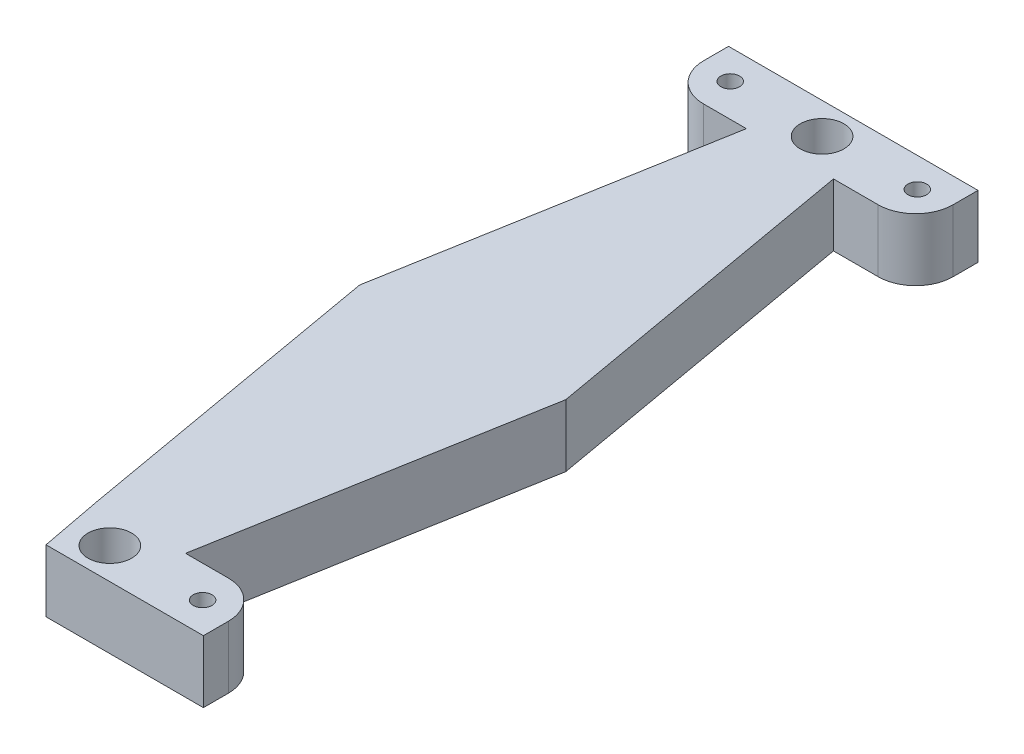
from build123d import *

# Parameters (mm, degrees)
SKETCH2_R           = 1.5
SKETCH2_R_2         = 3.5
SKETCH2_W           = 40
SKETCH2_H           = 10
BOSS_EXTRUDE1_DEPTH = 10
FILLET1_R           = 6
CUT_EXTRUDE2_DEPTH  = 11


with BuildPart() as part:
    # Sketch2 → Boss-Extrude1 (new body)
    with BuildSketch(Plane(origin=(0, 0, 0), x_dir=(1, 0, 0), z_dir=(0, 1, 0))):
        Polygon((27.08938228, 113.93955974), (13.128576505, 113.93955974), (3.831784068, 61.214829812), (12.862340376, 10), (27.137659624, 10), (36.277195325, 61.83288266), align=None)
        Polygon((0.266236129, 113.93955974), (13.128576505, 113.93955974), (27.08938228, 113.93955974), (40.266236129, 113.93955974), (40.266236129, 123.93955974), (0.266236129, 123.93955974), align=None)
        with Locations((5.266236129, 119.206649777)):
            Circle(SKETCH2_R, mode=Mode.SUBTRACT)
        with Locations((20.266236129, 118.93955974)):
            Circle(SKETCH2_R_2, mode=Mode.SUBTRACT)
        with Locations((35.266236129, 119.206649777)):
            Circle(SKETCH2_R, mode=Mode.SUBTRACT)
        with Locations((20, 5)):
            Rectangle(SKETCH2_W, SKETCH2_H)
        with Locations((35, 4.874301968)):
            Circle(SKETCH2_R, mode=Mode.SUBTRACT)
        with Locations((5, 4.874301968)):
            Circle(SKETCH2_R, mode=Mode.SUBTRACT)
        with Locations((20, 5)):
            Circle(SKETCH2_R_2, mode=Mode.SUBTRACT)
    extrude(amount=BOSS_EXTRUDE1_DEPTH)

    # Fillet1
    fillet1_edges = [part.edges().sort_by_distance(p)[0] for p in [
        (40, 5, -10),
        (0, 5, -10),
        (0.266236129, 5, -113.93955974),
        (40.266236129, 5, -113.93955974),
    ]]
    fillet(fillet1_edges, radius=FILLET1_R)

    # Sketch3 → Cut-Extrude2 (cut, through all)
    with BuildSketch(Plane(origin=(0, 10, 0), x_dir=(1, 0, 0), z_dir=(0, 1, 0))):
        Polygon((14.761999195, 0), (0, 0), (0, 10.134747314), (12.862340376, 10), align=None)
    extrude(amount=-CUT_EXTRUDE2_DEPTH, mode=Mode.SUBTRACT)


solid = part.part
